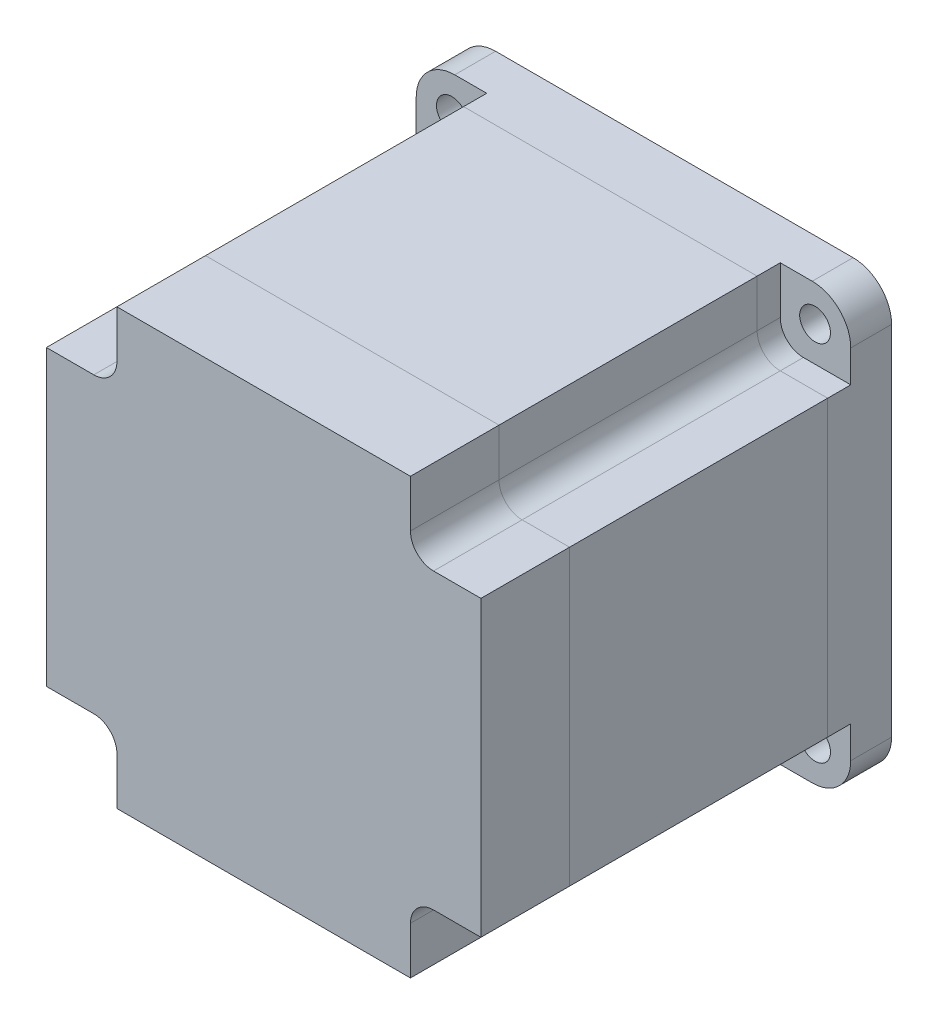
from build123d import *

# Parameters (mm, degrees)
CROQUIS1_R                = 2
SALIENTE_EXTRUIR1_DEPTH   = 5.3
SALIENTE_EXTRUIR2_DEPTH   = 3
SALIENTE_EXTRUIR4_DEPTH   = 33.5
SALIENTE_EXTRUIR7_DEPTH   = 11.5
CROQUIS7_R                = 19.05
CROQUIS7_R_2              = 15.25
SALIENTE_EXTRUIR9_DEPTH   = 1.6
CROQUIS7_R_3              = 12.55
CROQUIS7_R_4              = 5
SALIENTE_EXTRUIR9_2_DEPTH = 1.6
CROQUIS8_R                = 3.2
SALIENTE_EXTRUIR10_DEPTH  = 24


with BuildPart() as part:
    # Croquis1 → Saliente-Extruir1 (new body)
    with BuildSketch(Plane.XY):
        with BuildLine():
            Line((23.2, -28.2), (-23.2, -28.2))
            ThreePointArc((-23.2, -28.2), (-26.735533906, -26.735533906), (-28.2, -23.2))
            Line((-28.2, -23.2), (-28.2, 23.2))
            ThreePointArc((-28.2, 23.2), (-26.735533906, 26.735533906), (-23.2, 28.2))
            Line((-23.2, 28.2), (23.2, 28.2))
            ThreePointArc((23.2, 28.2), (26.735533906, 26.735533906), (28.2, 23.2))
            Line((28.2, 23.2), (28.2, -23.2))
            ThreePointArc((28.2, -23.2), (26.735533906, -26.735533906), (23.2, -28.2))
        make_face()
        with Locations((-23.57, -23.57)):
            Circle(CROQUIS1_R, mode=Mode.SUBTRACT)
        with Locations((23.57, -23.57)):
            Circle(CROQUIS1_R, mode=Mode.SUBTRACT)
        with Locations((-23.57, 23.57)):
            Circle(CROQUIS1_R, mode=Mode.SUBTRACT)
        with Locations((23.57, 23.57)):
            Circle(CROQUIS1_R, mode=Mode.SUBTRACT)
    extrude(amount=SALIENTE_EXTRUIR1_DEPTH)

    # Croquis2 → Saliente-Extruir2 (add)
    with BuildSketch(Plane.XY.offset(5.3)):
        with BuildLine():
            Line((-19.05, 22.05), (-19.05, 28.2))
            Line((-19.05, 28.2), (19.05, 28.2))
            Line((19.05, 28.2), (19.05, 22.05))
            ThreePointArc((19.05, 22.05), (19.928679656, 19.928679656), (22.05, 19.05))
            Line((22.05, 19.05), (28.2, 19.05))
            Line((28.2, 19.05), (28.2, -19.05))
            Line((28.2, -19.05), (22.05, -19.05))
            ThreePointArc((22.05, -19.05), (19.928679656, -19.928679656), (19.05, -22.05))
            Line((19.05, -22.05), (19.05, -28.2))
            Line((19.05, -28.2), (-19.05, -28.2))
            Line((-19.05, -28.2), (-19.05, -22.05))
            ThreePointArc((-19.05, -22.05), (-19.928679656, -19.928679656), (-22.05, -19.05))
            Line((-22.05, -19.05), (-28.2, -19.05))
            Line((-28.2, -19.05), (-28.2, 19.05))
            Line((-28.2, 19.05), (-22.05, 19.05))
            ThreePointArc((-22.05, 19.05), (-19.928679656, 19.928679656), (-19.05, 22.05))
        make_face()
    extrude(amount=SALIENTE_EXTRUIR2_DEPTH)



with BuildPart() as body_2:
    # Croquis3 → Saliente-Extruir4 (new body)
    with BuildSketch(Plane.XY.offset(8.3)):
        with BuildLine():
            Line((-19.05, 28.2), (19.05, 28.2))
            Line((19.05, 28.2), (19.05, 22.05))
            ThreePointArc((19.05, 22.05), (19.928679656, 19.928679656), (22.05, 19.05))
            Line((22.05, 19.05), (28.2, 19.05))
            Line((28.2, 19.05), (28.2, -19.05))
            Line((28.2, -19.05), (22.05, -19.05))
            ThreePointArc((22.05, -19.05), (19.928679656, -19.928679656), (19.05, -22.05))
            Line((19.05, -22.05), (19.05, -28.2))
            Line((19.05, -28.2), (-19.05, -28.2))
            Line((-19.05, -28.2), (-19.05, -22.05))
            ThreePointArc((-19.05, -22.05), (-19.928679656, -19.928679656), (-22.05, -19.05))
            Line((-22.05, -19.05), (-28.2, -19.05))
            Line((-28.2, -19.05), (-28.2, 19.05))
            Line((-28.2, 19.05), (-22.05, 19.05))
            ThreePointArc((-22.05, 19.05), (-19.928679656, 19.928679656), (-19.05, 22.05))
            Line((-19.05, 22.05), (-19.05, 28.2))
        make_face()
    extrude(amount=SALIENTE_EXTRUIR4_DEPTH)


with BuildPart() as body_3:
    # Croquis5 → Saliente-Extruir7 (new body)
    with BuildSketch(Plane.XY.offset(41.8)):
        with BuildLine():
            Line((22.05, 19.05), (28.2, 19.05))
            Line((28.2, 19.05), (28.2, -19.05))
            Line((28.2, -19.05), (22.05, -19.05))
            ThreePointArc((22.05, -19.05), (19.928679656, -19.928679656), (19.05, -22.05))
            Line((19.05, -22.05), (19.05, -28.2))
            Line((19.05, -28.2), (-19.05, -28.2))
            Line((-19.05, -28.2), (-19.05, -22.05))
            ThreePointArc((-19.05, -22.05), (-19.928679656, -19.928679656), (-22.05, -19.05))
            Line((-22.05, -19.05), (-28.2, -19.05))
            Line((-28.2, -19.05), (-28.2, 19.05))
            Line((-28.2, 19.05), (-22.05, 19.05))
            ThreePointArc((-22.05, 19.05), (-19.928679656, 19.928679656), (-19.05, 22.05))
            Line((-19.05, 22.05), (-19.05, 28.2))
            Line((-19.05, 28.2), (19.05, 28.2))
            Line((19.05, 28.2), (19.05, 22.05))
            ThreePointArc((19.05, 22.05), (19.928679656, 19.928679656), (22.05, 19.05))
        make_face()
    extrude(amount=SALIENTE_EXTRUIR7_DEPTH)


with BuildPart() as body_4:
    # Croquis7 → Saliente-Extruir9 (new body)
    with BuildSketch(Plane(origin=(0, 0, 0), x_dir=(-1, 0, 0), z_dir=(0, 0, -1))):
        Circle(CROQUIS7_R)
        Circle(CROQUIS7_R_2, mode=Mode.SUBTRACT)
    extrude(amount=SALIENTE_EXTRUIR9_DEPTH)


with BuildPart() as body_5:
    # Croquis7 → Saliente-Extruir9 2 (new body)
    with BuildSketch(Plane(origin=(0, 0, 0), x_dir=(-1, 0, 0), z_dir=(0, 0, -1))):
        Circle(CROQUIS7_R_3)
        Circle(CROQUIS7_R_4, mode=Mode.SUBTRACT)
    extrude(amount=SALIENTE_EXTRUIR9_2_DEPTH)


with BuildPart() as part_1:
    add(part.part)

    add(body_4.part)  # Saliente-Extruir10 merges body 4

    add(body_5.part)  # Saliente-Extruir10 merges body 5
    # Croquis8 → Saliente-Extruir10 (add)
    with BuildSketch(Plane(origin=(0, 0, 0), x_dir=(-1, 0, 0), z_dir=(0, 0, -1))):
        with Locations(Location((0, 0, 0), (0, 0, 180))):
            Circle(CROQUIS8_R)
    extrude(amount=SALIENTE_EXTRUIR10_DEPTH)


solid = Compound([body_2.part, body_3.part, part_1.part])
